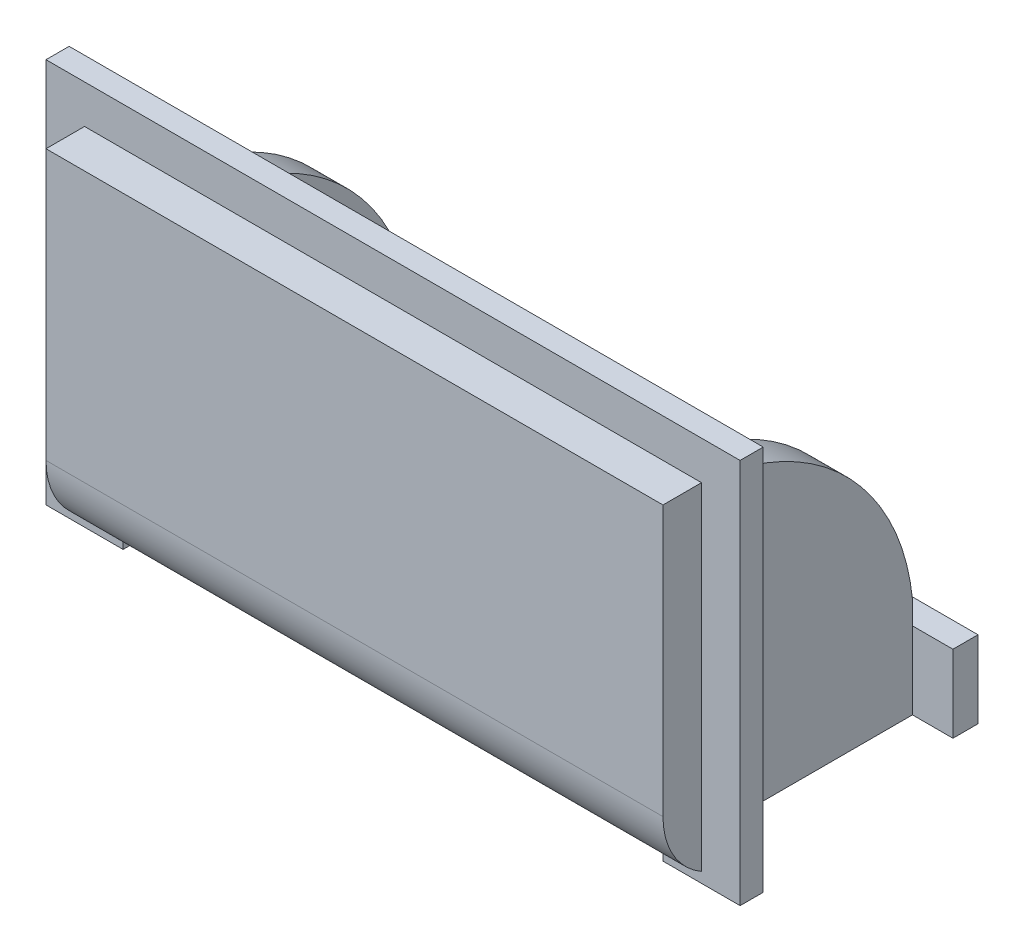
from build123d import *

# Parameters (mm, degrees)
BOSS_EXTRUDE1_DEPTH      = 3
BOSS_EXTRUDE2_START      = 0.25
SKETCH2_W                = 3
SKETCH2_H                = 29.75
BOSS_EXTRUDE2_DEPTH      = 5
SKETCH2_6_W              = 5
SKETCH2_6_H              = 45
SKETCH2_6_W_2            = 3.25
SKETCH2_6_H_2            = 10
BOSS_EXTRUDE5_DEPTH      = 75
BOSS_EXTRUDE5_DEPTH_BACK = 5
BOSS_EXTRUDE6_START      = 65
SKETCH2_8_W              = 3
SKETCH2_8_H              = 29.75
BOSS_EXTRUDE6_DEPTH      = 4.75
BOSS_EXTRUDE8_START      = 0.25
SKETCH2_9_W              = 3
SKETCH2_9_H              = 10
SKETCH2_9_W_2            = 29.598352995
BOSS_EXTRUDE8_DEPTH      = 69.5
FILLET1_R                = 10
SKETCH3_W                = 17.7
SKETCH3_H                = 25.7
SKETCH3_R                = 1.5
CUT_EXTRUDE1_DEPTH       = 6


with BuildPart() as part:
    # Sketch1 → Boss-Extrude1 (new body)
    with BuildSketch(Plane.XY):
        Polygon((45, -20), (35, -20), (35, 20), (-35, 20), (-35, -20), (-45, -20), (-45, 30), (45, 30), align=None)
    extrude(amount=BOSS_EXTRUDE1_DEPTH)


with BuildPart() as body_2:
    # Sketch2 → Boss-Extrude2 (new body)
    with BuildSketch(Plane.ZY.offset(-35).offset(BOSS_EXTRUDE2_START)):
        with BuildLine():
            Line((-29.598352995, -10), (0, -10))
            Line((0, -10), (0, 19.75))
            ThreePointArc((0, 19.75), (-19.947587573, 12.071616388), (-29.598352995, -7))
            Line((-29.598352995, -7), (-29.598352995, -10))
        make_face()
        with Locations((1.5, 4.875)):
            Rectangle(SKETCH2_W, SKETCH2_H)
    extrude(amount=BOSS_EXTRUDE2_DEPTH)

    # Sketch2_6 → Boss-Extrude5 (add, two sides)
    with BuildSketch(Plane.ZY.offset(-35)) as boss_extrude5_sk:
        with Locations((5.5, 2.5)):
            Rectangle(SKETCH2_6_W, SKETCH2_6_H)
        with Locations((-31.223352995, -15)):
            Rectangle(SKETCH2_6_W_2, SKETCH2_6_H_2)
    extrude(amount=BOSS_EXTRUDE5_DEPTH)
    extrude(boss_extrude5_sk.sketch, amount=-BOSS_EXTRUDE5_DEPTH_BACK)

    # Sketch2_8 → Boss-Extrude6 (add)
    with BuildSketch(Plane.ZY.offset(-35).offset(BOSS_EXTRUDE6_START)):
        with BuildLine():
            Line((-29.598352995, -10), (0, -10))
            Line((0, -10), (0, 19.75))
            ThreePointArc((0, 19.75), (-19.947587573, 12.071616388), (-29.598352995, -7))
            Line((-29.598352995, -7), (-29.598352995, -10))
        make_face()
        with Locations((1.5, 4.875)):
            Rectangle(SKETCH2_8_W, SKETCH2_8_H)
    extrude(amount=BOSS_EXTRUDE6_DEPTH)

    # Sketch2_9 → Boss-Extrude8 (add)
    with BuildSketch(Plane.ZY.offset(-35).offset(BOSS_EXTRUDE8_START)):
        with Locations((1.5, -15)):
            Rectangle(SKETCH2_9_W, SKETCH2_9_H)
        with Locations((-14.799176498, -15)):
            Rectangle(SKETCH2_9_W_2, SKETCH2_9_H)
    extrude(amount=BOSS_EXTRUDE8_DEPTH)

    # Fillet1
    fillet1_edges = [body_2.edges().sort_by_distance(p)[0] for p in [
        (0, -20, 8),
    ]]
    fillet(fillet1_edges, radius=FILLET1_R)

    # Sketch3 → Cut-Extrude1 (cut)
    with BuildSketch(Plane.XZ.offset(20)):
        with Locations((0, -19.998352995)):
            Rectangle(SKETCH3_W, SKETCH3_H)
        with Locations(Location((-5.85, -10.148352995, 0), (0, 0, 270))):  # turned: the seam where the file's is
            Circle(SKETCH3_R, mode=Mode.SUBTRACT)
        with Locations(Location((-5.85, -29.848352995, 0), (0, 0, 270))):  # turned: the seam where the file's is
            Circle(SKETCH3_R, mode=Mode.SUBTRACT)
        with Locations(Location((5.85, -29.848352995, 0), (0, 0, 90))):  # turned: the seam where the file's is
            Circle(SKETCH3_R, mode=Mode.SUBTRACT)
        with Locations(Location((5.85, -10.148352995, 0), (0, 0, 90))):  # turned: the seam where the file's is
            Circle(SKETCH3_R, mode=Mode.SUBTRACT)
    extrude(amount=-CUT_EXTRUDE1_DEPTH, mode=Mode.SUBTRACT)


solid = Compound([part.part, body_2.part])
